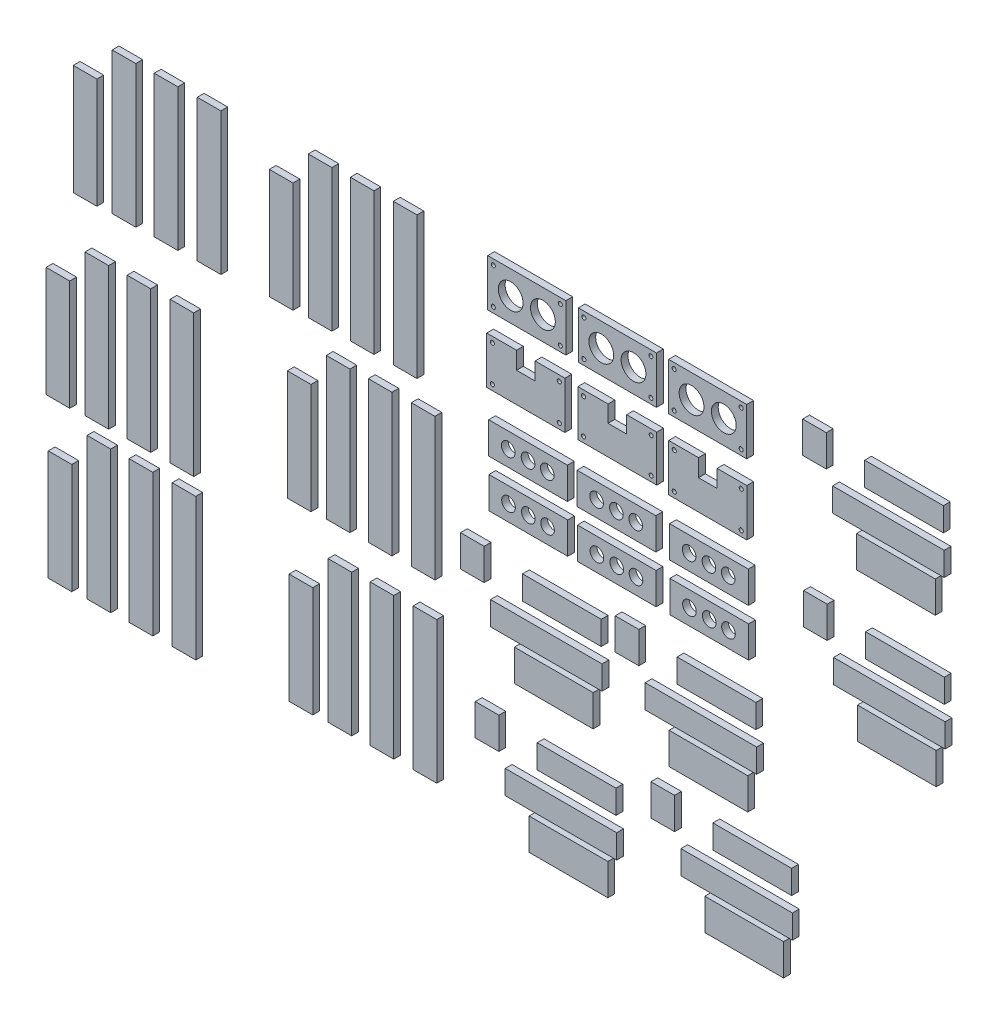
from build123d import *

# Parameters (mm, degrees)
CROQUIS1_W                 = 63
CROQUIS1_H                 = 38
CROQUIS1_R                 = 1.65
CROQUIS1_R_2               = 10
SALIENTE_EXTRUIR1_DEPTH    = 5.5
SALIENTE_EXTRUIR1_2_DEPTH  = 5.5
SALIENTE_EXTRUIR1_3_DEPTH  = 5.5
SALIENTE_EXTRUIR1_4_DEPTH  = 5.5
SALIENTE_EXTRUIR1_5_DEPTH  = 5.5
SALIENTE_EXTRUIR1_6_DEPTH  = 5.5
CROQUIS1_W_2               = 19.05
CROQUIS1_H_2               = 114.3
SALIENTE_EXTRUIR1_7_DEPTH  = 5.5
SALIENTE_EXTRUIR1_8_DEPTH  = 5.5
SALIENTE_EXTRUIR1_9_DEPTH  = 5.5
CROQUIS1_H_3               = 88.9
SALIENTE_EXTRUIR1_10_DEPTH = 5.5
CROQUIS1_W_3               = 89.916
CROQUIS1_H_4               = 19.05
SALIENTE_EXTRUIR1_11_DEPTH = 5.5
CROQUIS1_W_4               = 63.5
CROQUIS1_H_5               = 25.4
CROQUIS1_R_3               = 5.5
SALIENTE_EXTRUIR1_12_DEPTH = 5.5
SALIENTE_EXTRUIR1_13_DEPTH = 5.5
SALIENTE_EXTRUIR1_14_DEPTH = 5.5
SALIENTE_EXTRUIR1_15_DEPTH = 5.5
SALIENTE_EXTRUIR1_16_DEPTH = 5.5
SALIENTE_EXTRUIR1_17_DEPTH = 5.5
SALIENTE_EXTRUIR1_18_DEPTH = 5.5
SALIENTE_EXTRUIR1_19_DEPTH = 5.5
SALIENTE_EXTRUIR1_20_DEPTH = 5.5
SALIENTE_EXTRUIR1_21_DEPTH = 5.5
SALIENTE_EXTRUIR1_22_DEPTH = 5.5
SALIENTE_EXTRUIR1_23_DEPTH = 5.5
SALIENTE_EXTRUIR1_24_DEPTH = 5.5
SALIENTE_EXTRUIR1_25_DEPTH = 5.5
SALIENTE_EXTRUIR1_26_DEPTH = 5.5
SALIENTE_EXTRUIR1_27_DEPTH = 5.5
SALIENTE_EXTRUIR1_28_DEPTH = 5.5
SALIENTE_EXTRUIR1_29_DEPTH = 5.5
SALIENTE_EXTRUIR1_30_DEPTH = 5.5
SALIENTE_EXTRUIR1_31_DEPTH = 5.5
SALIENTE_EXTRUIR1_32_DEPTH = 5.5
SALIENTE_EXTRUIR1_33_DEPTH = 5.5
SALIENTE_EXTRUIR1_34_DEPTH = 5.5
SALIENTE_EXTRUIR1_35_DEPTH = 5.5
SALIENTE_EXTRUIR1_36_DEPTH = 5.5
SALIENTE_EXTRUIR1_37_DEPTH = 5.5
SALIENTE_EXTRUIR1_38_DEPTH = 5.5
SALIENTE_EXTRUIR1_39_DEPTH = 5.5
SALIENTE_EXTRUIR1_40_DEPTH = 5.5
SALIENTE_EXTRUIR1_41_DEPTH = 5.5
SALIENTE_EXTRUIR1_42_DEPTH = 5.5
SALIENTE_EXTRUIR1_43_DEPTH = 5.5
SALIENTE_EXTRUIR1_44_DEPTH = 5.5
SALIENTE_EXTRUIR1_45_DEPTH = 5.5
SALIENTE_EXTRUIR1_46_DEPTH = 5.5
SALIENTE_EXTRUIR1_47_DEPTH = 5.5
SALIENTE_EXTRUIR1_48_DEPTH = 5.5
SALIENTE_EXTRUIR1_49_DEPTH = 5.5
SALIENTE_EXTRUIR1_50_DEPTH = 5.5
SALIENTE_EXTRUIR1_51_DEPTH = 5.5
SALIENTE_EXTRUIR1_52_DEPTH = 5.5
SALIENTE_EXTRUIR1_53_DEPTH = 5.5
SALIENTE_EXTRUIR1_54_DEPTH = 5.5
SALIENTE_EXTRUIR1_55_DEPTH = 5.5
SALIENTE_EXTRUIR1_56_DEPTH = 5.5
SALIENTE_EXTRUIR1_57_DEPTH = 5.5
SALIENTE_EXTRUIR1_58_DEPTH = 5.5
SALIENTE_EXTRUIR1_59_DEPTH = 5.5
SALIENTE_EXTRUIR1_60_DEPTH = 5.5


with BuildPart() as part:
    # Croquis1 → Saliente-Extruir1 (new body)
    with BuildSketch(Plane.XY):
        Rectangle(CROQUIS1_W, CROQUIS1_H)
        with Locations((27, 14.5)):
            Circle(CROQUIS1_R, mode=Mode.SUBTRACT)
        with Locations((13, 0)):
            Circle(CROQUIS1_R_2, mode=Mode.SUBTRACT)
        with Locations((-13, 0)):
            Circle(CROQUIS1_R_2, mode=Mode.SUBTRACT)
        with Locations((27, -14.5)):
            Circle(CROQUIS1_R, mode=Mode.SUBTRACT)
        with Locations((-27, -14.5)):
            Circle(CROQUIS1_R, mode=Mode.SUBTRACT)
        with Locations((-27, 14.5)):
            Circle(CROQUIS1_R, mode=Mode.SUBTRACT)
    extrude(amount=SALIENTE_EXTRUIR1_DEPTH)


with BuildPart() as body_2:
    # Croquis1 → Saliente-Extruir1 2 (new body)
    with BuildSketch(Plane.XY):
        with Locations((-72.812610645, -0.465446214)):
            Rectangle(CROQUIS1_W, CROQUIS1_H)
        with Locations((-45.812610645, 14.034553786)):
            Circle(CROQUIS1_R, mode=Mode.SUBTRACT)
        with Locations((-59.812610645, -0.465446214)):
            Circle(CROQUIS1_R_2, mode=Mode.SUBTRACT)
        with Locations((-85.812610645, -0.465446214)):
            Circle(CROQUIS1_R_2, mode=Mode.SUBTRACT)
        with Locations((-45.812610645, -14.965446214)):
            Circle(CROQUIS1_R, mode=Mode.SUBTRACT)
        with Locations((-99.812610645, -14.965446214)):
            Circle(CROQUIS1_R, mode=Mode.SUBTRACT)
        with Locations((-99.812610645, 14.034553786)):
            Circle(CROQUIS1_R, mode=Mode.SUBTRACT)
    extrude(amount=SALIENTE_EXTRUIR1_2_DEPTH)


with BuildPart() as body_3:
    # Croquis1 → Saliente-Extruir1 3 (new body)
    with BuildSketch(Plane.XY):
        with Locations((-145.86711144, -0.465446214)):
            Rectangle(CROQUIS1_W, CROQUIS1_H)
        with Locations((-118.86711144, 14.034553786)):
            Circle(CROQUIS1_R, mode=Mode.SUBTRACT)
        with Locations((-132.86711144, -0.465446214)):
            Circle(CROQUIS1_R_2, mode=Mode.SUBTRACT)
        with Locations((-158.86711144, -0.465446214)):
            Circle(CROQUIS1_R_2, mode=Mode.SUBTRACT)
        with Locations((-118.86711144, -14.965446214)):
            Circle(CROQUIS1_R, mode=Mode.SUBTRACT)
        with Locations((-172.86711144, -14.965446214)):
            Circle(CROQUIS1_R, mode=Mode.SUBTRACT)
        with Locations((-172.86711144, 14.034553786)):
            Circle(CROQUIS1_R, mode=Mode.SUBTRACT)
    extrude(amount=SALIENTE_EXTRUIR1_3_DEPTH)


with BuildPart() as body_4:
    # Croquis1 → Saliente-Extruir1 4 (new body)
    with BuildSketch(Plane.XY):
        Polygon((-178.168236764, -73.964902623), (-162.168236764, -73.964902623), (-131.168236764, -73.964902623), (-115.168236764, -73.964902623), (-115.168236764, -35.964902623), (-139.168236764, -35.964902623), (-139.168236764, -49.964902623), (-154.168236764, -49.964902623), (-154.168236764, -35.964902623), (-178.168236764, -35.964902623), align=None)
        with Locations((-119.668236764, -40.464902623)):
            Circle(CROQUIS1_R, mode=Mode.SUBTRACT)
        with Locations((-173.668236764, -40.464902623)):
            Circle(CROQUIS1_R, mode=Mode.SUBTRACT)
        with Locations((-173.668236764, -69.464902623)):
            Circle(CROQUIS1_R, mode=Mode.SUBTRACT)
        with Locations((-119.668236764, -69.464902623)):
            Circle(CROQUIS1_R, mode=Mode.SUBTRACT)
    extrude(amount=SALIENTE_EXTRUIR1_4_DEPTH)


with BuildPart() as body_5:
    # Croquis1 → Saliente-Extruir1 5 (new body)
    with BuildSketch(Plane.XY):
        Polygon((-104.643801794, -73.633711474), (-88.643801794, -73.633711474), (-57.643801794, -73.633711474), (-41.07162485, -73.633711474), (-41.07162485, -36.592103179), (-65.357713322, -36.592103179), (-65.357713322, -50.112907327), (-80.357713322, -50.112907327), (-80.357713322, -36.592103179), (-104.643801794, -36.592103179), align=None)
        with Locations((-45.57162485, -41.092103179)):
            Circle(CROQUIS1_R, mode=Mode.SUBTRACT)
        with Locations((-100.143801794, -41.092103179)):
            Circle(CROQUIS1_R, mode=Mode.SUBTRACT)
        with Locations((-100.143801794, -69.133711474)):
            Circle(CROQUIS1_R, mode=Mode.SUBTRACT)
        with Locations((-45.57162485, -69.133711474)):
            Circle(CROQUIS1_R, mode=Mode.SUBTRACT)
    extrude(amount=SALIENTE_EXTRUIR1_5_DEPTH)


with BuildPart() as body_6:
    # Croquis1 → Saliente-Extruir1 6 (new body)
    with BuildSketch(Plane.XY):
        Polygon((-31.450557972, -75.620858365), (-15.450557972, -75.620858365), (15.549442028, -75.620858365), (31.549442028, -75.620858365), (31.549442028, -37.620858365), (7.549442028, -37.620858365), (7.549442028, -51.620858365), (-7.450557972, -51.620858365), (-7.450557972, -37.620858365), (-31.450557972, -37.620858365), align=None)
        with Locations((27.049442028, -42.120858365)):
            Circle(CROQUIS1_R, mode=Mode.SUBTRACT)
        with Locations((-26.950557972, -42.120858365)):
            Circle(CROQUIS1_R, mode=Mode.SUBTRACT)
        with Locations((-26.950557972, -71.120858365)):
            Circle(CROQUIS1_R, mode=Mode.SUBTRACT)
        with Locations((27.049442028, -71.120858365)):
            Circle(CROQUIS1_R, mode=Mode.SUBTRACT)
    extrude(amount=SALIENTE_EXTRUIR1_6_DEPTH)


with BuildPart() as body_7:
    # Croquis1 → Saliente-Extruir1 7 (new body)
    with BuildSketch(Plane.XY):
        with Locations((-278.661320086, -39.276971888)):
            Rectangle(CROQUIS1_W_2, CROQUIS1_H_2)
    extrude(amount=SALIENTE_EXTRUIR1_7_DEPTH)


with BuildPart() as body_8:
    # Croquis1 → Saliente-Extruir1 8 (new body)
    with BuildSketch(Plane.XY):
        with Locations((-243.962714995, -38.740922673)):
            Rectangle(CROQUIS1_W_2, CROQUIS1_H_2)
    extrude(amount=SALIENTE_EXTRUIR1_8_DEPTH)


with BuildPart() as body_9:
    # Croquis1 → Saliente-Extruir1 9 (new body)
    with BuildSketch(Plane.XY):
        with Locations((-312.556182028, -39.990547929)):
            Rectangle(CROQUIS1_W_2, CROQUIS1_H_2)
    extrude(amount=SALIENTE_EXTRUIR1_9_DEPTH)


with BuildPart() as body_10:
    # Croquis1 → Saliente-Extruir1 10 (new body)
    with BuildSketch(Plane.XY):
        with Locations((-343.953527827, -53.76091199)):
            Rectangle(CROQUIS1_W_2, CROQUIS1_H_3)
    extrude(amount=SALIENTE_EXTRUIR1_10_DEPTH)


with BuildPart() as body_11:
    # Croquis1 → Saliente-Extruir1 11 (new body)
    with BuildSketch(Plane.XY):
        with Locations((-5.457469806, -225.791174145)):
            Rectangle(CROQUIS1_W_3, CROQUIS1_H_4)
    extrude(amount=SALIENTE_EXTRUIR1_11_DEPTH)


with BuildPart() as body_12:
    # Croquis1 → Saliente-Extruir1 12 (new body)
    with BuildSketch(Plane.XY):
        with Locations((-144.867678391, -108.41438594)):
            Rectangle(CROQUIS1_W_4, CROQUIS1_H_5)
        with Locations((-160.848873007, -108.41438594)):
            Circle(CROQUIS1_R_3, mode=Mode.SUBTRACT)
        with Locations((-144.867678391, -108.41438594)):
            Circle(CROQUIS1_R_3, mode=Mode.SUBTRACT)
        with Locations((-129.34992093, -108.41438594)):
            Circle(CROQUIS1_R_3, mode=Mode.SUBTRACT)
    extrude(amount=SALIENTE_EXTRUIR1_12_DEPTH)


with BuildPart() as body_13:
    # Croquis1 → Saliente-Extruir1 13 (new body)
    with BuildSketch(Plane.XY):
        with Locations((7.124579179, -194.934034612)):
            Rectangle(CROQUIS1_W_4, CROQUIS1_H_4)
    extrude(amount=SALIENTE_EXTRUIR1_13_DEPTH)


with BuildPart() as body_14:
    # Croquis1 → Saliente-Extruir1 14 (new body)
    with BuildSketch(Plane.XY):
        with Locations((-73.580455503, -108.044020729)):
            Rectangle(CROQUIS1_W_4, CROQUIS1_H_5)
        with Locations((-89.56165012, -108.044020729)):
            Circle(CROQUIS1_R_3, mode=Mode.SUBTRACT)
        with Locations((-73.580455503, -108.044020729)):
            Circle(CROQUIS1_R_3, mode=Mode.SUBTRACT)
        with Locations((-58.062698042, -108.044020729)):
            Circle(CROQUIS1_R_3, mode=Mode.SUBTRACT)
    extrude(amount=SALIENTE_EXTRUIR1_14_DEPTH)


with BuildPart() as body_15:
    # Croquis1 → Saliente-Extruir1 15 (new body)
    with BuildSketch(Plane.XY):
        with Locations((0.584658586, -252.564452909)):
            Rectangle(CROQUIS1_W_4, CROQUIS1_H_5)
    extrude(amount=SALIENTE_EXTRUIR1_15_DEPTH)


with BuildPart() as body_16:
    # Croquis1 → Saliente-Extruir1 16 (new body)
    with BuildSketch(Plane.XY):
        with Locations((-65.060948054, -194.341366733)):
            Rectangle(CROQUIS1_W_2, CROQUIS1_H_5)
    extrude(amount=SALIENTE_EXTRUIR1_16_DEPTH)


with BuildPart() as body_17:
    # Croquis1 → Saliente-Extruir1 17 (new body)
    with BuildSketch(Plane.XY):
        with Locations((1.013834969, -108.044020729)):
            Rectangle(CROQUIS1_W_4, CROQUIS1_H_5)
        with Locations((-14.967359647, -108.044020729)):
            Circle(CROQUIS1_R_3, mode=Mode.SUBTRACT)
        with Locations((1.013834969, -108.044020729)):
            Circle(CROQUIS1_R_3, mode=Mode.SUBTRACT)
        with Locations((16.53159243, -108.044020729)):
            Circle(CROQUIS1_R_3, mode=Mode.SUBTRACT)
    extrude(amount=SALIENTE_EXTRUIR1_17_DEPTH)


with BuildPart() as body_18:
    # Croquis1 → Saliente-Extruir1 18 (new body)
    with BuildSketch(Plane.XY):
        with Locations((-144.629417082, -146.553444659)):
            Rectangle(CROQUIS1_W_4, CROQUIS1_H_5)
        with Locations((-160.610611698, -146.553444659)):
            Circle(CROQUIS1_R_3, mode=Mode.SUBTRACT)
        with Locations((-144.629417082, -146.553444659)):
            Circle(CROQUIS1_R_3, mode=Mode.SUBTRACT)
        with Locations((-129.111659621, -146.553444659)):
            Circle(CROQUIS1_R_3, mode=Mode.SUBTRACT)
    extrude(amount=SALIENTE_EXTRUIR1_18_DEPTH)


with BuildPart() as body_19:
    # Croquis1 → Saliente-Extruir1 19 (new body)
    with BuildSketch(Plane.XY):
        with Locations((-73.342194194, -146.183079448)):
            Rectangle(CROQUIS1_W_4, CROQUIS1_H_5)
        with Locations((-89.323388811, -146.183079448)):
            Circle(CROQUIS1_R_3, mode=Mode.SUBTRACT)
        with Locations((-73.342194194, -146.183079448)):
            Circle(CROQUIS1_R_3, mode=Mode.SUBTRACT)
        with Locations((-57.824436733, -146.183079448)):
            Circle(CROQUIS1_R_3, mode=Mode.SUBTRACT)
    extrude(amount=SALIENTE_EXTRUIR1_19_DEPTH)


with BuildPart() as body_20:
    # Croquis1 → Saliente-Extruir1 20 (new body)
    with BuildSketch(Plane.XY):
        with Locations((1.252096278, -146.183079448)):
            Rectangle(CROQUIS1_W_4, CROQUIS1_H_5)
        with Locations((-14.729098338, -146.183079448)):
            Circle(CROQUIS1_R_3, mode=Mode.SUBTRACT)
        with Locations((1.252096278, -146.183079448)):
            Circle(CROQUIS1_R_3, mode=Mode.SUBTRACT)
        with Locations((16.769853739, -146.183079448)):
            Circle(CROQUIS1_R_3, mode=Mode.SUBTRACT)
    extrude(amount=SALIENTE_EXTRUIR1_20_DEPTH)


with BuildPart() as body_21:
    # Croquis1 → Saliente-Extruir1 21 (new body)
    with BuildSketch(Plane.XY):
        with Locations((-436.781265133, -45.717598425)):
            Rectangle(CROQUIS1_W_2, CROQUIS1_H_2)
    extrude(amount=SALIENTE_EXTRUIR1_21_DEPTH)


with BuildPart() as body_22:
    # Croquis1 → Saliente-Extruir1 22 (new body)
    with BuildSketch(Plane.XY):
        with Locations((-402.082660042, -45.181549209)):
            Rectangle(CROQUIS1_W_2, CROQUIS1_H_2)
    extrude(amount=SALIENTE_EXTRUIR1_22_DEPTH)


with BuildPart() as body_23:
    # Croquis1 → Saliente-Extruir1 23 (new body)
    with BuildSketch(Plane.XY):
        with Locations((-470.676127076, -46.431174466)):
            Rectangle(CROQUIS1_W_2, CROQUIS1_H_2)
    extrude(amount=SALIENTE_EXTRUIR1_23_DEPTH)


with BuildPart() as body_24:
    # Croquis1 → Saliente-Extruir1 24 (new body)
    with BuildSketch(Plane.XY):
        with Locations((-502.073472875, -60.201538527)):
            Rectangle(CROQUIS1_W_2, CROQUIS1_H_3)
    extrude(amount=SALIENTE_EXTRUIR1_24_DEPTH)


with BuildPart() as body_25:
    # Croquis1 → Saliente-Extruir1 25 (new body)
    with BuildSketch(Plane.XY):
        with Locations((-458.675449327, -197.725791538)):
            Rectangle(CROQUIS1_W_2, CROQUIS1_H_2)
    extrude(amount=SALIENTE_EXTRUIR1_25_DEPTH)


with BuildPart() as body_26:
    # Croquis1 → Saliente-Extruir1 26 (new body)
    with BuildSketch(Plane.XY):
        with Locations((-423.976844235, -197.189742323)):
            Rectangle(CROQUIS1_W_2, CROQUIS1_H_2)
    extrude(amount=SALIENTE_EXTRUIR1_26_DEPTH)


with BuildPart() as body_27:
    # Croquis1 → Saliente-Extruir1 27 (new body)
    with BuildSketch(Plane.XY):
        with Locations((-492.570311269, -198.439367579)):
            Rectangle(CROQUIS1_W_2, CROQUIS1_H_2)
    extrude(amount=SALIENTE_EXTRUIR1_27_DEPTH)


with BuildPart() as body_28:
    # Croquis1 → Saliente-Extruir1 28 (new body)
    with BuildSketch(Plane.XY):
        with Locations((-523.967657068, -212.209731641)):
            Rectangle(CROQUIS1_W_2, CROQUIS1_H_3)
    extrude(amount=SALIENTE_EXTRUIR1_28_DEPTH)


with BuildPart() as body_29:
    # Croquis1 → Saliente-Extruir1 29 (new body)
    with BuildSketch(Plane.XY):
        with Locations((-264.129984066, -172.703866746)):
            Rectangle(CROQUIS1_W_2, CROQUIS1_H_2)
    extrude(amount=SALIENTE_EXTRUIR1_29_DEPTH)


with BuildPart() as body_30:
    # Croquis1 → Saliente-Extruir1 30 (new body)
    with BuildSketch(Plane.XY):
        with Locations((-229.431378975, -172.167817531)):
            Rectangle(CROQUIS1_W_2, CROQUIS1_H_2)
    extrude(amount=SALIENTE_EXTRUIR1_30_DEPTH)


with BuildPart() as body_31:
    # Croquis1 → Saliente-Extruir1 31 (new body)
    with BuildSketch(Plane.XY):
        with Locations((-298.024846008, -173.417442787)):
            Rectangle(CROQUIS1_W_2, CROQUIS1_H_2)
    extrude(amount=SALIENTE_EXTRUIR1_31_DEPTH)


with BuildPart() as body_32:
    # Croquis1 → Saliente-Extruir1 32 (new body)
    with BuildSketch(Plane.XY):
        with Locations((-329.422191807, -187.187806848)):
            Rectangle(CROQUIS1_W_2, CROQUIS1_H_3)
    extrude(amount=SALIENTE_EXTRUIR1_32_DEPTH)


with BuildPart() as body_33:
    # Croquis1 → Saliente-Extruir1 33 (new body)
    with BuildSketch(Plane.XY):
        with Locations((-457.009155579, -325.027814307)):
            Rectangle(CROQUIS1_W_2, CROQUIS1_H_2)
    extrude(amount=SALIENTE_EXTRUIR1_33_DEPTH)


with BuildPart() as body_34:
    # Croquis1 → Saliente-Extruir1 34 (new body)
    with BuildSketch(Plane.XY):
        with Locations((-422.310550488, -324.491765092)):
            Rectangle(CROQUIS1_W_2, CROQUIS1_H_2)
    extrude(amount=SALIENTE_EXTRUIR1_34_DEPTH)


with BuildPart() as body_35:
    # Croquis1 → Saliente-Extruir1 35 (new body)
    with BuildSketch(Plane.XY):
        with Locations((-490.904017521, -325.741390348)):
            Rectangle(CROQUIS1_W_2, CROQUIS1_H_2)
    extrude(amount=SALIENTE_EXTRUIR1_35_DEPTH)


with BuildPart() as body_36:
    # Croquis1 → Saliente-Extruir1 36 (new body)
    with BuildSketch(Plane.XY):
        with Locations((-522.30136332, -339.511754409)):
            Rectangle(CROQUIS1_W_2, CROQUIS1_H_3)
    extrude(amount=SALIENTE_EXTRUIR1_36_DEPTH)


with BuildPart() as body_37:
    # Croquis1 → Saliente-Extruir1 37 (new body)
    with BuildSketch(Plane.XY):
        with Locations((-262.687466973, -313.902526791)):
            Rectangle(CROQUIS1_W_2, CROQUIS1_H_2)
    extrude(amount=SALIENTE_EXTRUIR1_37_DEPTH)


with BuildPart() as body_38:
    # Croquis1 → Saliente-Extruir1 38 (new body)
    with BuildSketch(Plane.XY):
        with Locations((-227.988861881, -313.366477576)):
            Rectangle(CROQUIS1_W_2, CROQUIS1_H_2)
    extrude(amount=SALIENTE_EXTRUIR1_38_DEPTH)


with BuildPart() as body_39:
    # Croquis1 → Saliente-Extruir1 39 (new body)
    with BuildSketch(Plane.XY):
        with Locations((-296.582328915, -314.616102832)):
            Rectangle(CROQUIS1_W_2, CROQUIS1_H_2)
    extrude(amount=SALIENTE_EXTRUIR1_39_DEPTH)


with BuildPart() as body_40:
    # Croquis1 → Saliente-Extruir1 40 (new body)
    with BuildSketch(Plane.XY):
        with Locations((-327.979674714, -328.386466894)):
            Rectangle(CROQUIS1_W_2, CROQUIS1_H_3)
    extrude(amount=SALIENTE_EXTRUIR1_40_DEPTH)


with BuildPart() as body_41:
    # Croquis1 → Saliente-Extruir1 41 (new body)
    with BuildSketch(Plane.XY):
        with Locations((-130.170521483, -230.087493938)):
            Rectangle(CROQUIS1_W_3, CROQUIS1_H_4)
    extrude(amount=SALIENTE_EXTRUIR1_41_DEPTH)


with BuildPart() as body_42:
    # Croquis1 → Saliente-Extruir1 42 (new body)
    with BuildSketch(Plane.XY):
        with Locations((-117.588472498, -199.230354404)):
            Rectangle(CROQUIS1_W_4, CROQUIS1_H_4)
    extrude(amount=SALIENTE_EXTRUIR1_42_DEPTH)


with BuildPart() as body_43:
    # Croquis1 → Saliente-Extruir1 43 (new body)
    with BuildSketch(Plane.XY):
        with Locations((-124.128393091, -256.860772701)):
            Rectangle(CROQUIS1_W_4, CROQUIS1_H_5)
    extrude(amount=SALIENTE_EXTRUIR1_43_DEPTH)


with BuildPart() as body_44:
    # Croquis1 → Saliente-Extruir1 44 (new body)
    with BuildSketch(Plane.XY):
        with Locations((-189.773999731, -198.637686525)):
            Rectangle(CROQUIS1_W_2, CROQUIS1_H_5)
    extrude(amount=SALIENTE_EXTRUIR1_44_DEPTH)


with BuildPart() as body_45:
    # Croquis1 → Saliente-Extruir1 45 (new body)
    with BuildSketch(Plane.XY):
        with Locations((-118.303548133, -342.082054928)):
            Rectangle(CROQUIS1_W_3, CROQUIS1_H_4)
    extrude(amount=SALIENTE_EXTRUIR1_45_DEPTH)


with BuildPart() as body_46:
    # Croquis1 → Saliente-Extruir1 46 (new body)
    with BuildSketch(Plane.XY):
        with Locations((-105.721499147, -311.224915395)):
            Rectangle(CROQUIS1_W_4, CROQUIS1_H_4)
    extrude(amount=SALIENTE_EXTRUIR1_46_DEPTH)


with BuildPart() as body_47:
    # Croquis1 → Saliente-Extruir1 47 (new body)
    with BuildSketch(Plane.XY):
        with Locations((-112.261419741, -368.855333692)):
            Rectangle(CROQUIS1_W_4, CROQUIS1_H_5)
    extrude(amount=SALIENTE_EXTRUIR1_47_DEPTH)


with BuildPart() as body_48:
    # Croquis1 → Saliente-Extruir1 48 (new body)
    with BuildSketch(Plane.XY):
        with Locations((-177.907026381, -310.632247516)):
            Rectangle(CROQUIS1_W_2, CROQUIS1_H_5)
    extrude(amount=SALIENTE_EXTRUIR1_48_DEPTH)


with BuildPart() as body_49:
    # Croquis1 → Saliente-Extruir1 49 (new body)
    with BuildSketch(Plane.XY):
        with Locations((23.358446233, -327.248338241)):
            Rectangle(CROQUIS1_W_3, CROQUIS1_H_4)
    extrude(amount=SALIENTE_EXTRUIR1_49_DEPTH)


with BuildPart() as body_50:
    # Croquis1 → Saliente-Extruir1 50 (new body)
    with BuildSketch(Plane.XY):
        with Locations((35.940495218, -296.391198707)):
            Rectangle(CROQUIS1_W_4, CROQUIS1_H_4)
    extrude(amount=SALIENTE_EXTRUIR1_50_DEPTH)


with BuildPart() as body_51:
    # Croquis1 → Saliente-Extruir1 51 (new body)
    with BuildSketch(Plane.XY):
        with Locations((29.400574625, -354.021617004)):
            Rectangle(CROQUIS1_W_4, CROQUIS1_H_5)
    extrude(amount=SALIENTE_EXTRUIR1_51_DEPTH)


with BuildPart() as body_52:
    # Croquis1 → Saliente-Extruir1 52 (new body)
    with BuildSketch(Plane.XY):
        with Locations((-36.245032015, -295.798530828)):
            Rectangle(CROQUIS1_W_2, CROQUIS1_H_5)
    extrude(amount=SALIENTE_EXTRUIR1_52_DEPTH)


with BuildPart() as body_53:
    # Croquis1 → Saliente-Extruir1 53 (new body)
    with BuildSketch(Plane.XY):
        with Locations((145.736608905, -12.773544465)):
            Rectangle(CROQUIS1_W_3, CROQUIS1_H_4)
    extrude(amount=SALIENTE_EXTRUIR1_53_DEPTH)


with BuildPart() as body_54:
    # Croquis1 → Saliente-Extruir1 54 (new body)
    with BuildSketch(Plane.XY):
        with Locations((158.31865789, 18.083595068)):
            Rectangle(CROQUIS1_W_4, CROQUIS1_H_4)
    extrude(amount=SALIENTE_EXTRUIR1_54_DEPTH)


with BuildPart() as body_55:
    # Croquis1 → Saliente-Extruir1 55 (new body)
    with BuildSketch(Plane.XY):
        with Locations((151.778737297, -39.546823229)):
            Rectangle(CROQUIS1_W_4, CROQUIS1_H_5)
    extrude(amount=SALIENTE_EXTRUIR1_55_DEPTH)


with BuildPart() as body_56:
    # Croquis1 → Saliente-Extruir1 56 (new body)
    with BuildSketch(Plane.XY):
        with Locations((86.133130657, 18.676262947)):
            Rectangle(CROQUIS1_W_2, CROQUIS1_H_5)
    extrude(amount=SALIENTE_EXTRUIR1_56_DEPTH)


with BuildPart() as body_57:
    # Croquis1 → Saliente-Extruir1 57 (new body)
    with BuildSketch(Plane.XY):
        with Locations((146.478294739, -132.1849638)):
            Rectangle(CROQUIS1_W_3, CROQUIS1_H_4)
    extrude(amount=SALIENTE_EXTRUIR1_57_DEPTH)


with BuildPart() as body_58:
    # Croquis1 → Saliente-Extruir1 58 (new body)
    with BuildSketch(Plane.XY):
        with Locations((159.060343725, -101.327824267)):
            Rectangle(CROQUIS1_W_4, CROQUIS1_H_4)
    extrude(amount=SALIENTE_EXTRUIR1_58_DEPTH)


with BuildPart() as body_59:
    # Croquis1 → Saliente-Extruir1 59 (new body)
    with BuildSketch(Plane.XY):
        with Locations((152.520423131, -158.958242563)):
            Rectangle(CROQUIS1_W_4, CROQUIS1_H_5)
    extrude(amount=SALIENTE_EXTRUIR1_59_DEPTH)


with BuildPart() as body_60:
    # Croquis1 → Saliente-Extruir1 60 (new body)
    with BuildSketch(Plane.XY):
        with Locations((86.874816491, -100.735156387)):
            Rectangle(CROQUIS1_W_2, CROQUIS1_H_5)
    extrude(amount=SALIENTE_EXTRUIR1_60_DEPTH)


solid = Compound([part.part, body_2.part, body_3.part, body_4.part, body_5.part, body_6.part, body_7.part, body_8.part, body_9.part, body_10.part, body_11.part, body_12.part, body_13.part, body_14.part, body_15.part, body_16.part, body_17.part, body_18.part, body_19.part, body_20.part, body_21.part, body_22.part, body_23.part, body_24.part, body_25.part, body_26.part, body_27.part, body_28.part, body_29.part, body_30.part, body_31.part, body_32.part, body_33.part, body_34.part, body_35.part, body_36.part, body_37.part, body_38.part, body_39.part, body_40.part, body_41.part, body_42.part, body_43.part, body_44.part, body_45.part, body_46.part, body_47.part, body_48.part, body_49.part, body_50.part, body_51.part, body_52.part, body_53.part, body_54.part, body_55.part, body_56.part, body_57.part, body_58.part, body_59.part, body_60.part])
